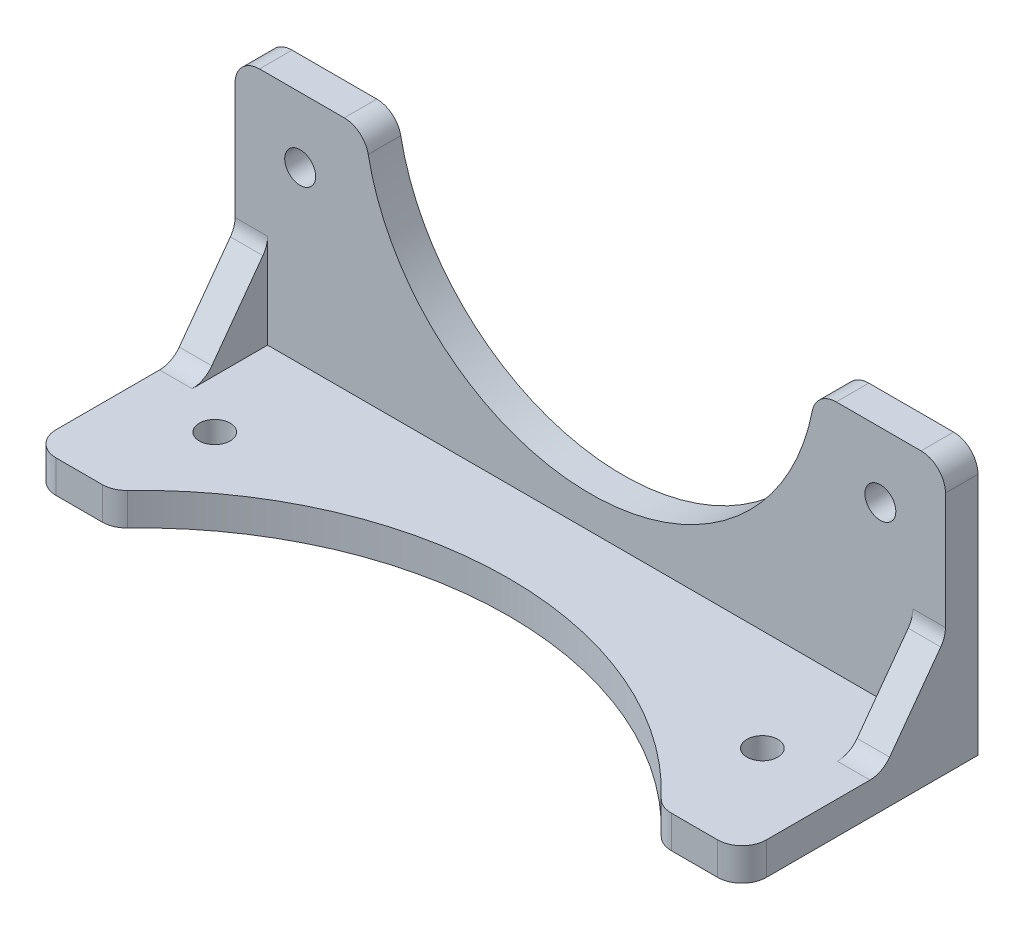
from build123d import *

# Parameters (mm, degrees)
SKETCH1_R      = 1.9
EXTRUDE1_DEPTH = 4
SKETCH2_R      = 1.9
EXTRUDE2_DEPTH = 4
EXTRUDE3_DEPTH = 4
FILLET1_R      = 3


with BuildPart() as part:
    # Sketch1 → Extrude1 (new body)
    with BuildSketch(Plane.XY):
        with BuildLine():
            Line((-43.65, 4.783810266), (-27.65, 4.783810266))
            ThreePointArc((-27.65, 4.783810266), (0, -20.116189734), (27.65, 4.783810266))
            Line((27.65, 4.783810266), (43.65, 4.783810266))
            Line((43.65, 4.783810266), (43.65, -28.116189734))
            Line((43.65, -28.116189734), (-43.65, -28.116189734))
            Line((-43.65, -28.116189734), (-43.65, 4.783810266))
        make_face()
        with Locations((-35.65, -3.216189734)):
            Circle(SKETCH1_R, mode=Mode.SUBTRACT)
        with Locations((35.65, -3.216189734)):
            Circle(SKETCH1_R, mode=Mode.SUBTRACT)
    extrude(amount=EXTRUDE1_DEPTH)



with BuildPart() as body_2:
    # Sketch2 → Extrude2 (new body)
    with BuildSketch(Plane.XZ.offset(28.116189734)):
        with BuildLine():
            Line((-33.65, 29), (-43.65, 29))
            Line((-43.65, 29), (-43.65, 4))
            Line((-43.65, 4), (43.65, 4))
            Line((43.65, 4), (43.65, 29))
            Line((43.65, 29), (33.65, 29))
            ThreePointArc((33.65, 29), (0, 14), (-33.65, 29))
        make_face()
        with Locations((-33.65, 16.5)):
            Circle(SKETCH2_R, mode=Mode.SUBTRACT)
        with Locations((33.65, 16.5)):
            Circle(SKETCH2_R, mode=Mode.SUBTRACT)
    extrude(amount=-EXTRUDE2_DEPTH)


with BuildPart() as part_1:
    add(part.part)

    add(body_2.part)  # Extrude3 merges body 2
    # Sketch3 → Extrude3 (add)
    with BuildSketch(Plane(origin=(43.65, 0, 0), x_dir=(0, 0, -1), z_dir=(1, 0, 0))):
        Polygon((-4, -24.116189734), (-11.756042517, -24.116189734), (-4, -13.510964822), align=None)
    extrude3 = extrude(amount=-EXTRUDE3_DEPTH)

    # Mirror1: Extrude3 across plane
    add(extrude3.mirror(Plane(origin=(0, 0, 0), x_dir=(0, 0, 1), z_dir=(1, 0, 0))))

    # Fillet1
    fillet1_edges = [part_1.edges().sort_by_distance(p)[0] for p in [
        (-43.65, 4.783810266, 2),
        (-27.65, 4.783810266, 2),
        (27.65, 4.783810266, 2),
        (43.65, 4.783810266, 2),
        (41.65, -13.510964822, 4),
        (41.65, -24.116189734, 11.756042517),
        (-33.65, -26.116189734, 29),
        (33.65, -26.116189734, 29),
        (43.65, -26.116189734, 29),
        (-43.65, -26.116189734, 29),
        (-41.65, -13.510964822, 4),
        (-41.65, -24.116189734, 11.756042517),
    ]]
    fillet(fillet1_edges, radius=FILLET1_R)


solid = part_1.part
